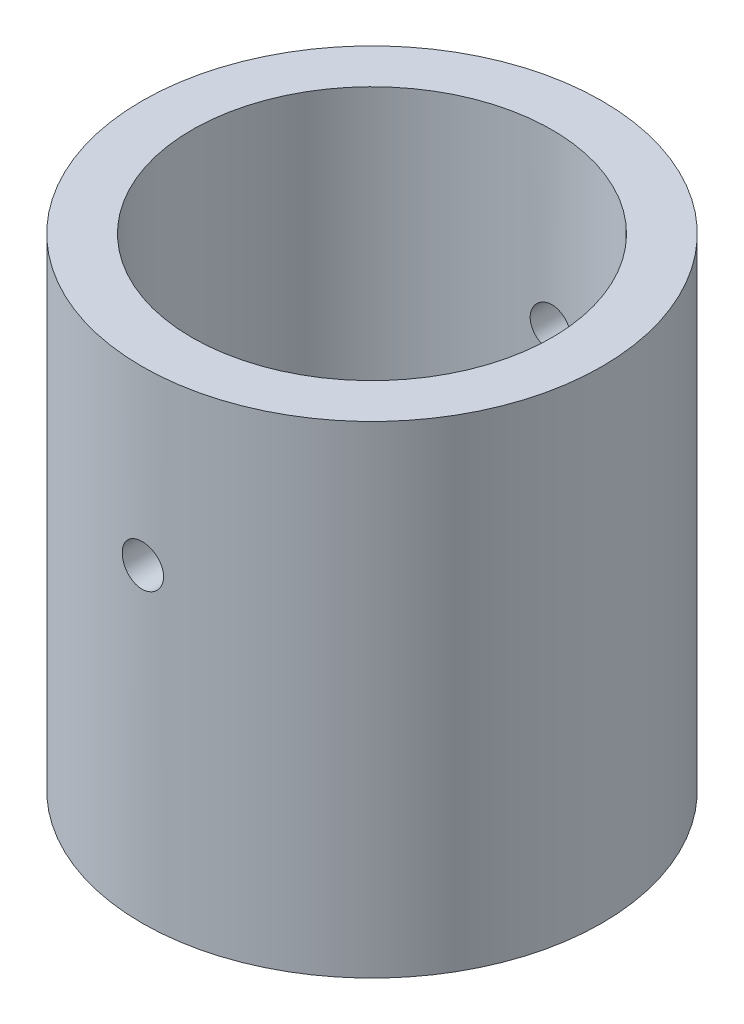
from build123d import *

# Parameters (mm, degrees)
SKETCH1_R                = 16.7005
SKETCH1_R_2              = 13.0683
BOSS_EXTRUDE1_DEPTH      = 25
BOSS_EXTRUDE1_DEPTH_BACK = 10
SKETCH3_R                = 1.5
CUT_EXTRUDE1_DEPTH       = 17.7005
CUT_EXTRUDE1_DEPTH_BACK  = 17.7005


with BuildPart() as part:
    # Sketch1 → Boss-Extrude1 (new body, two sides)
    with BuildSketch(Plane(origin=(0, 0, 0), x_dir=(1, 0, 0), z_dir=(0, 1, 0))) as boss_extrude1_sk:
        Circle(SKETCH1_R)
        Circle(SKETCH1_R_2, mode=Mode.SUBTRACT)
    extrude(amount=BOSS_EXTRUDE1_DEPTH)
    extrude(boss_extrude1_sk.sketch, amount=-BOSS_EXTRUDE1_DEPTH_BACK)

    # Sketch3 → Cut-Extrude1 (cut, two sides)
    with BuildSketch(Plane.XY) as cut_extrude1_sk:
        with Locations((0, 12.5)):
            Circle(SKETCH3_R)
    extrude(amount=CUT_EXTRUDE1_DEPTH, mode=Mode.SUBTRACT)
    extrude(cut_extrude1_sk.sketch, amount=-CUT_EXTRUDE1_DEPTH_BACK, mode=Mode.SUBTRACT)


solid = part.part
